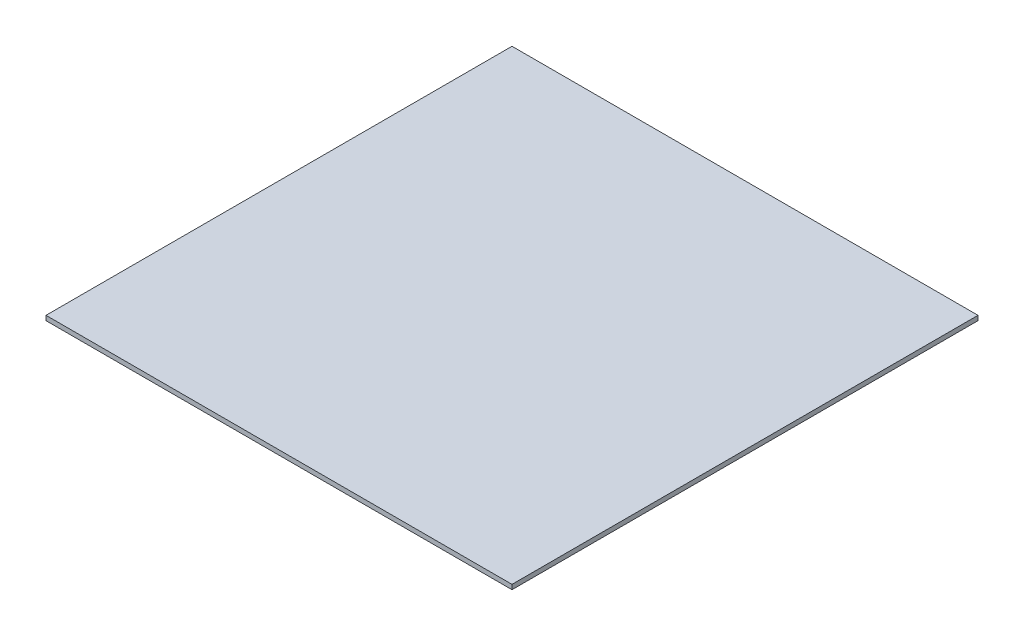
from build123d import *

# Parameters (mm, degrees)
ESQUISSE1_W        = 500
ESQUISSE1_H        = 500
BOSS_EXTRU_1_DEPTH = 5


with BuildPart() as part:
    # Esquisse1 → Boss.-Extru.1 (new body)
    with BuildSketch(Plane(origin=(0, 0, 0), x_dir=(1, 0, 0), z_dir=(0, 1, 0))):
        Rectangle(ESQUISSE1_W, ESQUISSE1_H)
    extrude(amount=BOSS_EXTRU_1_DEPTH)


solid = part.part
